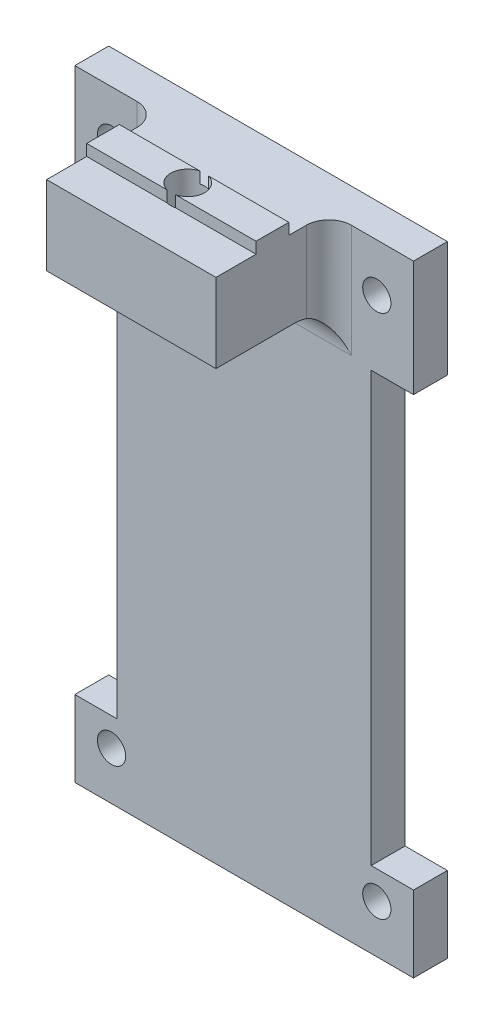
from build123d import *

# Parameters (mm, degrees)
SKETCH1_R              = 1.25
MAIN_DEPTH             = 3
MAKERBEAMSUPPORT_DEPTH = 7.5
FILLET1_R              = 3
FILLET2_R              = 2
SKETCH3_R              = 1.5
CUT_EXTRUDE1_DEPTH     = 57


with BuildPart() as part:
    # Sketch1 → Main (new body)
    with BuildSketch(Plane.XY):
        Polygon((-15, 55), (-15, 44.75), (-11.25, 44.75), (-11.25, 6.75), (-15, 6.75), (-15, 0), (15, 0), (15, 6.75), (11.25, 6.75), (11.25, 44.75), (15, 44.75), (15, 55), align=None)
        with Locations((-11.75, 50.75)):
            Circle(SKETCH1_R, mode=Mode.SUBTRACT)
        with Locations((11.75, 50.75)):
            Circle(SKETCH1_R, mode=Mode.SUBTRACT)
        with Locations((11.75, 4.25)):
            Circle(SKETCH1_R, mode=Mode.SUBTRACT)
        with Locations((-11.75, 4.25)):
            Circle(SKETCH1_R, mode=Mode.SUBTRACT)
    extrude(amount=MAIN_DEPTH)

    # Sketch2 → MakerBeamSupport (add, symmetric)
    with BuildSketch(Plane(origin=(0, 0, 0), x_dir=(0, 0, -1), z_dir=(1, 0, 0))):
        Polygon((-13, 55), (-9.45, 55), (-9.45, 56), (-6.55, 56), (-6.55, 55), (-3, 55), (-3, 48), (-13, 48), align=None)
    extrude(amount=MAKERBEAMSUPPORT_DEPTH, both=True)

    # Fillet1
    fillet1_edges = [part.edges().sort_by_distance(p)[0] for p in [
        (0, 48, 3),
    ]]
    fillet(fillet1_edges, radius=FILLET1_R)

    # Fillet2
    fillet2_edges = [part.edges().sort_by_distance(p)[0] for p in [
        (-7.5, 51.5, 3),
        (7.5, 51.5, 3),
    ]]
    fillet(fillet2_edges, radius=FILLET2_R)

    # Sketch3 → Cut-Extrude1 (cut, through all)
    with BuildSketch(Plane(origin=(0, 56, 0), x_dir=(1, 0, 0), z_dir=(0, 1, 0))):
        with Locations((0, -8)):
            Circle(SKETCH3_R)
    extrude(amount=-CUT_EXTRUDE1_DEPTH, mode=Mode.SUBTRACT)


solid = part.part
